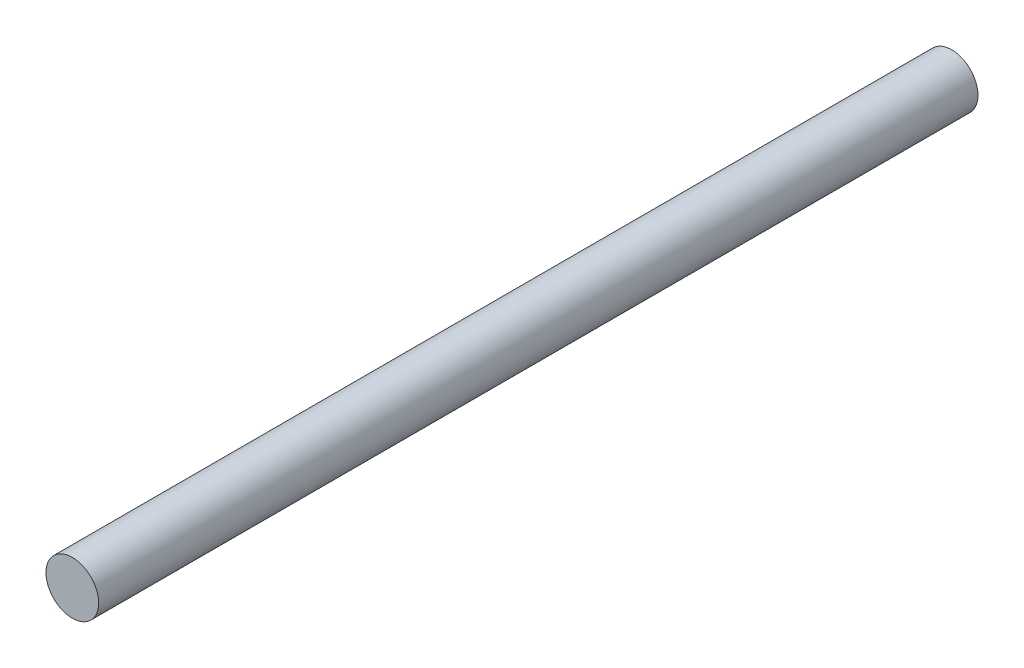
from build123d import *

# Parameters (mm, degrees)
SKETCH1_R           = 4.5
BOSS_EXTRUDE1_DEPTH = 150


with BuildPart() as part:
    # Sketch1 → Boss-Extrude1 (new body)
    with BuildSketch(Plane.XY):
        Circle(SKETCH1_R)
    extrude(amount=BOSS_EXTRUDE1_DEPTH)


solid = part.part
